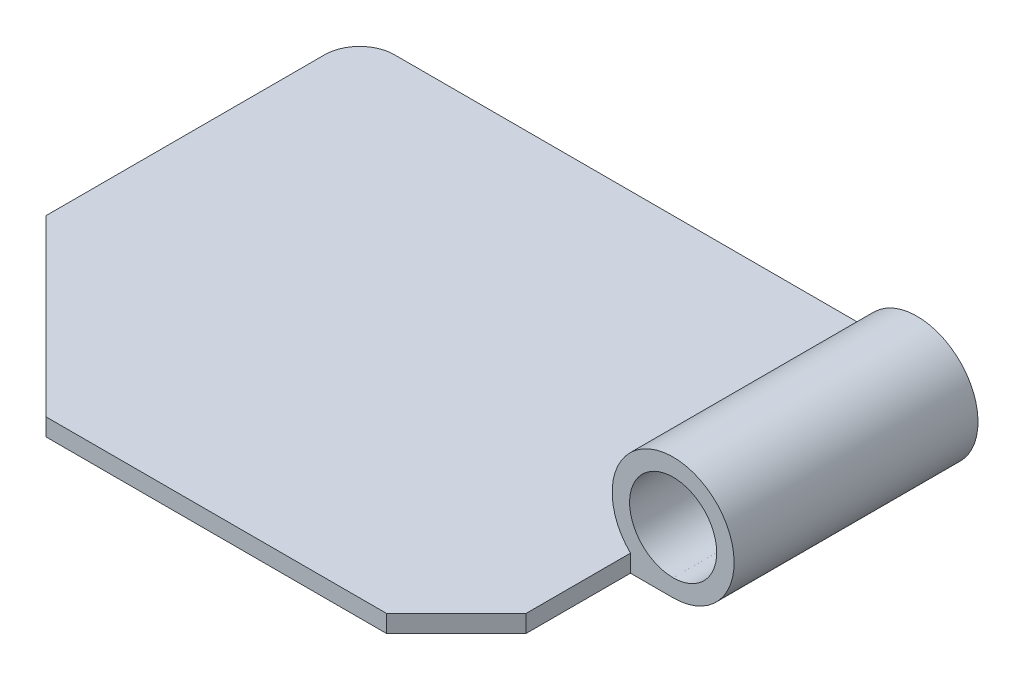
from build123d import *

# Parameters (mm, degrees)
BOSS_EXTRUDE1_DEPTH = 5
SKETCH2_R           = 17.5
SKETCH2_R_2         = 12.5
BOSS_EXTRUDE2_DEPTH = 70


with BuildPart() as part:
    # Sketch1 → Boss-Extrude1 (new body)
    with BuildSketch(Plane(origin=(0, 0, 0), x_dir=(1, 0, 0), z_dir=(0, 1, 0))):
        with BuildLine():
            Line((0, 0), (97.75, 0))
            Line((97.75, 0), (117.746979772, 19.996979772))
            Line((117.746979772, 19.996979772), (117.746979772, 49.996979772))
            Line((117.746979772, 49.996979772), (130.000479502, 49.996979772))
            Line((130.000479502, 49.996979772), (130.000479502, 119.996979772))
            Line((130.000479502, 119.996979772), (117.750479502, 119.996979772))
            Line((117.750479502, 119.996979772), (117.750479502, 139.999520498))
            Line((117.750479502, 139.999520498), (-39.999520498, 139.999520498))
            ThreePointArc((-39.999520498, 139.999520498), (-47.07058831, 137.07058831), (-49.999520498, 129.999520498))
            Line((-49.999520498, 129.999520498), (-49.999520498, 49.999520498))
            Line((-49.999520498, 49.999520498), (0, 0))
        make_face()
    extrude(amount=-BOSS_EXTRUDE1_DEPTH)

    # Sketch2 → Boss-Extrude2 (add)
    with BuildSketch(Plane(origin=(0, 0, -119.996979772), x_dir=(-1, 0, 0), z_dir=(0, 0, -1))):
        with Locations((-129.987472978, 12.499995167)):
            Circle(SKETCH2_R)
        with Locations((-129.987472978, 12.499995167)):
            Circle(SKETCH2_R_2, mode=Mode.SUBTRACT)
    extrude(amount=-BOSS_EXTRUDE2_DEPTH)


solid = part.part
